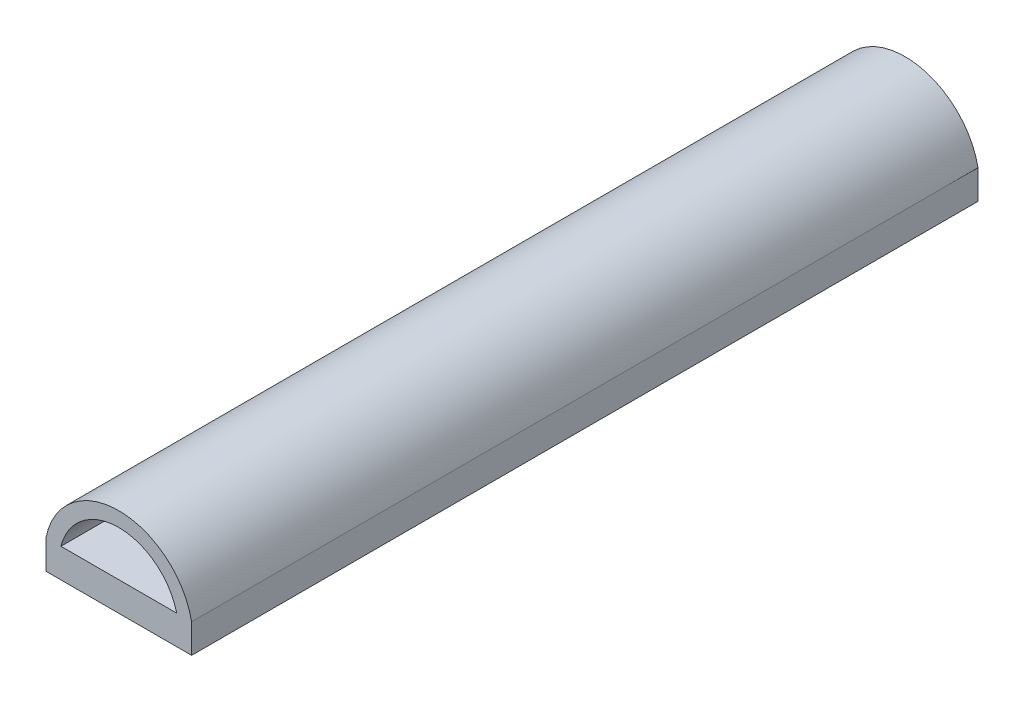
from build123d import *

# Parameters (mm, degrees)
BOSS_EXTRUDE1_DEPTH = 68.58
BOSS_EXTRUDE2_DEPTH = 25.4


with BuildPart() as part:
    # Sketch1 → Boss-Extrude1 (new body)
    with BuildSketch(Plane.XY):
        with BuildLine():
            Line((-6.35, 1.25906277), (-6.35, -1.28093723))
            Line((-6.35, -1.28093723), (6.35, -1.28093723))
            Line((6.35, -1.28093723), (6.35, 1.25906277))
            ThreePointArc((6.35, 1.25906277), (0, 6.473618699), (-6.35, 1.25906277))
        make_face()
        with BuildLine():
            Line((-5.049000743, 1.25906277), (5.049000743, 1.25906277))
            ThreePointArc((5.049000743, 1.25906277), (0, 5.203618699), (-5.049000743, 1.25906277))
        make_face(mode=Mode.SUBTRACT)
    extrude(amount=BOSS_EXTRUDE1_DEPTH)

    # Sketch3 → Boss-Extrude2 (add)
    with BuildSketch(Plane(origin=(0, 0, 0), x_dir=(-1, 0, 0), z_dir=(0, 0, -1))):
        Polygon((0.508, -1.28093723), (0.508, -3.37643723), (1.0795, -3.37643723), (1.0795, -4.26543723), (-1.0795, -4.26543723), (-1.0795, -3.37643723), (-0.508, -3.37643723), (-0.508, -1.28093723), align=None)
    extrude(amount=-BOSS_EXTRUDE2_DEPTH)


solid = part.part
